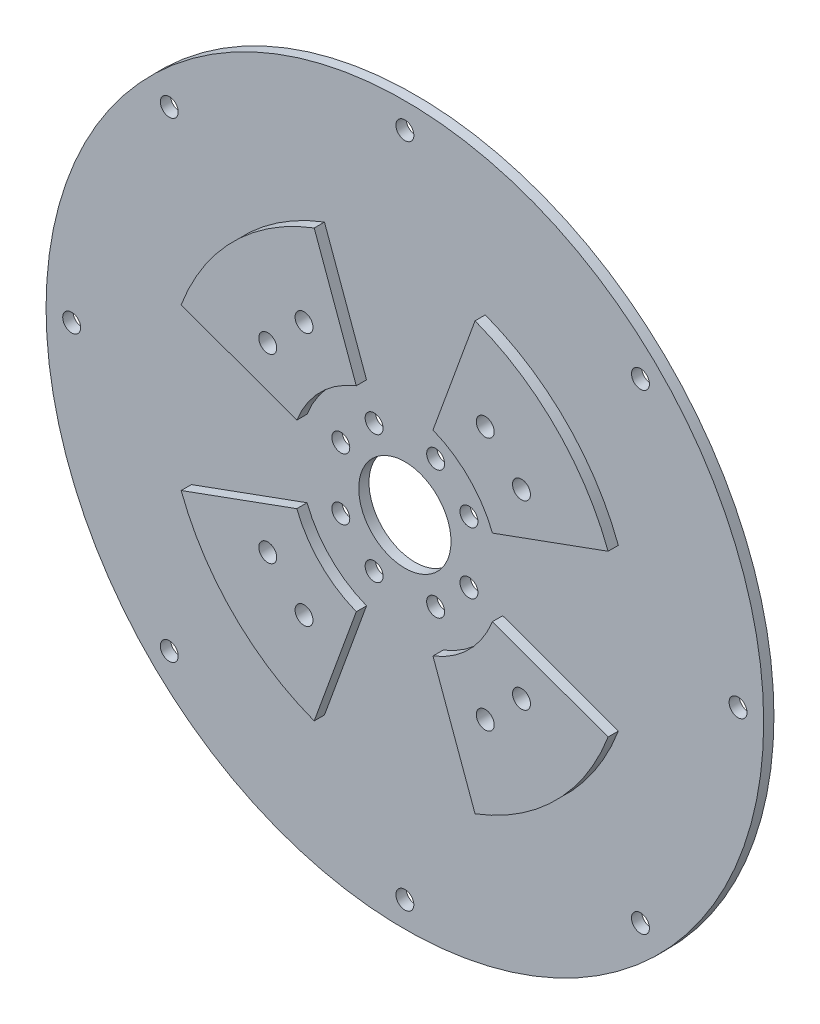
from build123d import *

# Parameters (mm, degrees)
SKETCH1_R           = 70
SKETCH1_R_2         = 9
BOSS_EXTRUDE1_DEPTH = 2
BOSS_EXTRUDE2_DEPTH = 2
SKETCH5_R           = 1.75
CUT_EXTRUDE4_DEPTH  = 5
CIRPATTERN1_COUNT   = 4
SKETCH3_R           = 1.75
CUT_EXTRUDE2_DEPTH  = 3
CIRPATTERN2_COUNT   = 2
CIRPATTERN2_ANGLE   = 90
SKETCH4_R           = 1.75
CUT_EXTRUDE3_DEPTH  = 3
CIRPATTERN3_COUNT   = 8


with BuildPart() as part:
    # Sketch1 → Boss-Extrude1 (new body)
    with BuildSketch(Plane.XY):
        Circle(SKETCH1_R)
        Circle(SKETCH1_R_2, mode=Mode.SUBTRACT)
    extrude(amount=BOSS_EXTRUDE1_DEPTH)

    # Sketch2 → Boss-Extrude2 (add)
    with BuildSketch(Plane.XY.offset(2)):
        with BuildLine():
            Line((7.47917345, 19.086957969), (15.688781927, 41.642671884))
            ThreePointArc((15.688781927, 41.642671884), (31.466251763, 31.466251763), (41.642671884, 15.688781927))
            Line((41.642671884, 15.688781927), (19.086957969, 7.47917345))
            ThreePointArc((19.086957969, 7.47917345), (14.495689014, 14.495689014), (7.47917345, 19.086957969))
        make_face()
    boss_extrude2 = extrude(amount=BOSS_EXTRUDE2_DEPTH)

    # Sketch5 → Cut-Extrude4 (cut, through all)
    with BuildSketch(Plane.XY.offset(4)):
        with Locations((17.67766953, 24.748737342)):
            Circle(SKETCH5_R)
        with Locations((24.748737342, 17.67766953)):
            Circle(SKETCH5_R)
    cut_extrude4 = extrude(amount=-CUT_EXTRUDE4_DEPTH, mode=Mode.SUBTRACT)

    # CirPattern1: Boss-Extrude2, Cut-Extrude4 ×4 about axis
    cirpattern1_axis = Axis((0, 0, 0), (0, 0, 1))
    for i in range(1, CIRPATTERN1_COUNT):
        add(boss_extrude2.rotate(cirpattern1_axis, i * 360 / CIRPATTERN1_COUNT))
        add(cut_extrude4.rotate(cirpattern1_axis, i * 360 / CIRPATTERN1_COUNT), mode=Mode.SUBTRACT)

    # Sketch3 → Cut-Extrude2 (cut, through all)
    with BuildSketch(Plane.XY.offset(2)):
        with Locations((-12.5, 6)):
            Circle(SKETCH3_R)
        with Locations((12.5, 6)):
            Circle(SKETCH3_R)
        with Locations((12.5, -6)):
            Circle(SKETCH3_R)
        with Locations((-12.5, -6)):
            Circle(SKETCH3_R)
    cut_extrude2 = extrude(amount=-CUT_EXTRUDE2_DEPTH, mode=Mode.SUBTRACT)

    # CirPattern2: Cut-Extrude2 ×2 about axis
    cirpattern2_axis = Axis((0, 0, 0), (0, 0, 1))
    for i in range(1, CIRPATTERN2_COUNT):
        add(cut_extrude2.rotate(cirpattern2_axis, i * CIRPATTERN2_ANGLE / (CIRPATTERN2_COUNT - 1)), mode=Mode.SUBTRACT)

    # Sketch4 → Cut-Extrude3 (cut, through all)
    with BuildSketch(Plane.XY.offset(2)):
        with Locations((0, 65)):
            Circle(SKETCH4_R)
    cut_extrude3 = extrude(amount=-CUT_EXTRUDE3_DEPTH, mode=Mode.SUBTRACT)

    # CirPattern3: Cut-Extrude3 ×8 about axis
    cirpattern3_axis = Axis((0, 0, 0), (0, 0, 1))
    for i in range(1, CIRPATTERN3_COUNT):
        add(cut_extrude3.rotate(cirpattern3_axis, i * 360 / CIRPATTERN3_COUNT), mode=Mode.SUBTRACT)


solid = part.part
